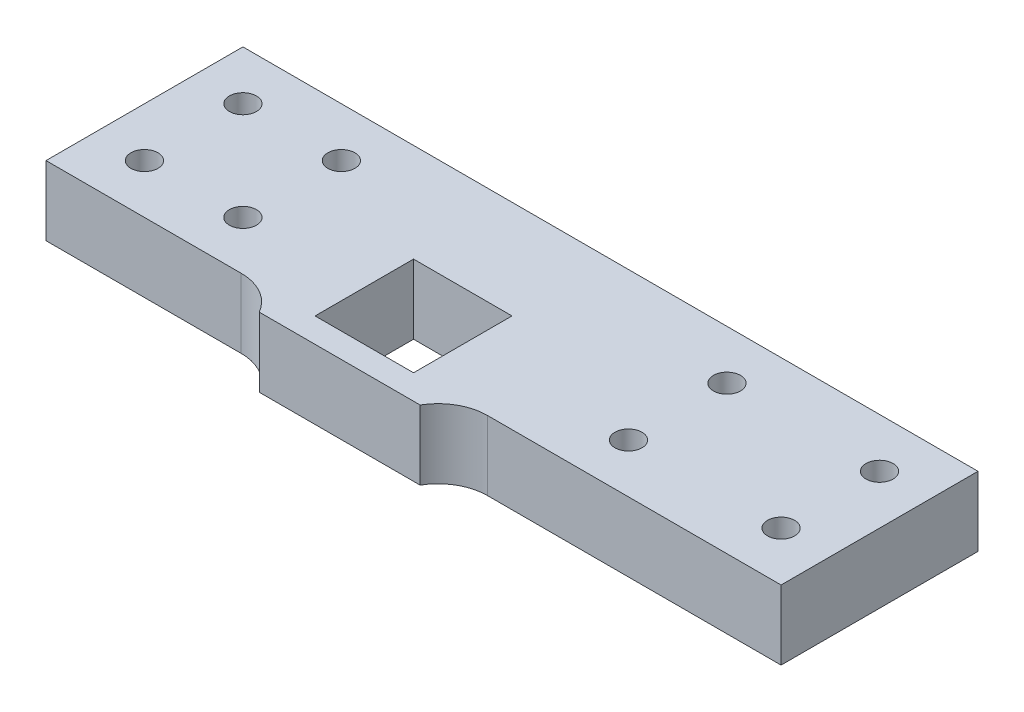
from build123d import *

# Parameters (mm, degrees)
SKETCH1_R            = 2.75
SKETCH1_W            = 20
SKETCH1_H            = 20
BOSS_EXTRUDE1_DEPTH  = 14.1
MOVE_FACE1_BY        = 20
SKETCH6_W            = 30.987343285
SKETCH6_H            = 33.189068773
BOSS_EXTRUDE2_DEPTH  = 14.1
M5_CLEARANCE_HOLE2_D = 5.5


with BuildPart() as part:
    # Sketch1 → Boss-Extrude1 (new body)
    with BuildSketch(Plane(origin=(0, 0, 0), x_dir=(1, 0, 0), z_dir=(0, 1, 0))):
        with BuildLine():
            Line((10, -22.5), (16.339745962, -22.5))
            ThreePointArc((16.339745962, -22.5), (20, -18.839745962), (25, -17.5))
            Line((25, -17.5), (64.66, -17.5))
            Line((64.66, -17.5), (64.66, 22.5))
            Line((64.66, 22.5), (-64.66, 22.5))
            Line((-64.66, 22.5), (-64.66, -17.5))
            Line((-64.66, -17.5), (-25, -17.5))
            ThreePointArc((-25, -17.5), (-20, -18.839745962), (-16.339745962, -22.5))
            Line((-16.339745962, -22.5), (-10, -22.5))
            Line((-10, -22.5), (10, -22.5))
        make_face()
        with Locations(Location((34.66, 12.5, 0), (0, 0, 270))):
            Circle(SKETCH1_R, mode=Mode.SUBTRACT)
        with Locations(Location((34.66, -7.5, 0), (0, 0, 270))):
            Circle(SKETCH1_R, mode=Mode.SUBTRACT)
        with Locations(Location((54.66, -7.5, 0), (0, 0, 270))):
            Circle(SKETCH1_R, mode=Mode.SUBTRACT)
        with Locations(Location((54.66, 12.5, 0), (0, 0, 270))):
            Circle(SKETCH1_R, mode=Mode.SUBTRACT)
        with Locations(Location((-54.66, -7.5, 0), (0, 0, 270))):
            Circle(SKETCH1_R, mode=Mode.SUBTRACT)
        with Locations(Location((-34.66, 12.5, 0), (0, 0, 270))):
            Circle(SKETCH1_R, mode=Mode.SUBTRACT)
        with Locations(Location((-54.66, 12.5, 0), (0, 0, 270))):
            Circle(SKETCH1_R, mode=Mode.SUBTRACT)
        with Locations(Location((-34.66, -7.5, 0), (0, 0, 270))):
            Circle(SKETCH1_R, mode=Mode.SUBTRACT)
        with Locations((0, -7.5)):
            Rectangle(SKETCH1_W, SKETCH1_H, mode=Mode.SUBTRACT)
    extrude(amount=BOSS_EXTRUDE1_DEPTH)

    # Move Face1: a face moved outward by 20.0
    extrude(part.faces().sort_by_distance((64.66, 7.05, -2.5))[0], amount=MOVE_FACE1_BY, dir=(1, 0, 0))

    # Sketch6 → Boss-Extrude2 (add)
    with BuildSketch(Plane.XZ):
        with Locations((43.846371015, -2.215029501)):
            Rectangle(SKETCH6_W, SKETCH6_H)
    extrude(amount=-BOSS_EXTRUDE2_DEPTH)

    # M5 Clearance Hole2 (through all)
    with Locations(Plane(origin=(0, 0, 0), x_dir=(-1, 0, 0), z_dir=(0, -1, 0))):
        with Locations((-74.66, -7.5), (-43.66, -7.5), (-43.66, 12.5), (-74.66, 12.5)):
            Hole(M5_CLEARANCE_HOLE2_D / 2)


solid = part.part
